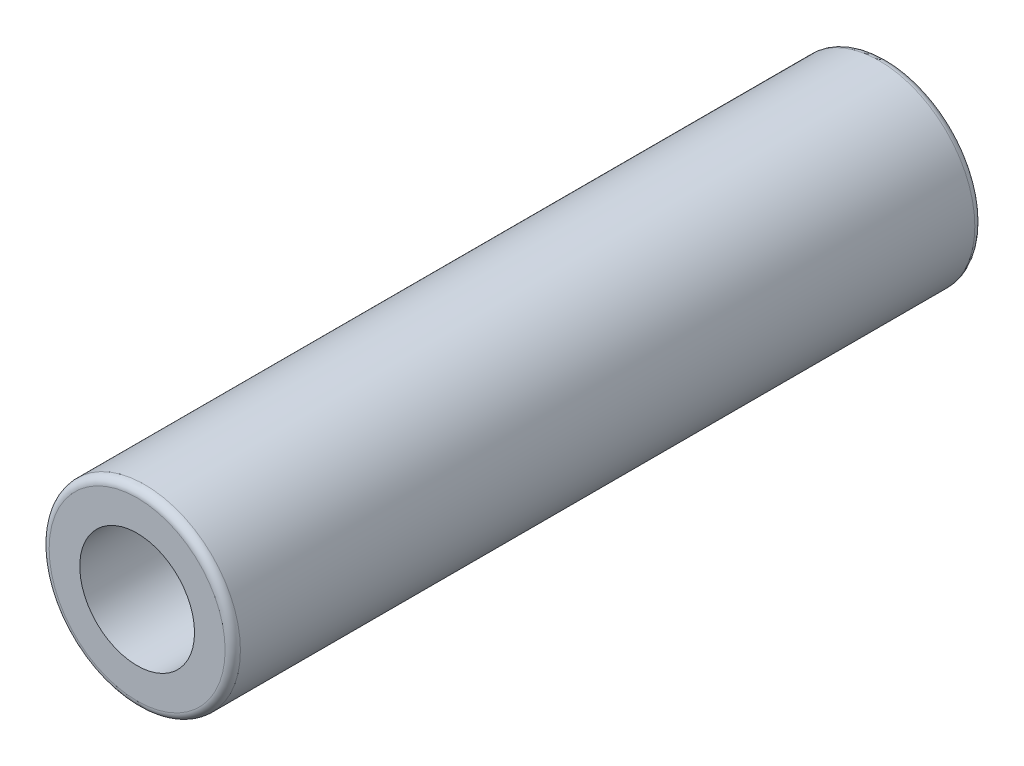
from build123d import *

# Parameters (mm, degrees)
SKETCH1_R           = 6.25
SKETCH1_R_2         = 3.75
EXTRUDE_THIN2_DEPTH = 24.5
FILLET4_R           = 0.5


with BuildPart() as part:
    # Sketch1 → Extrude-Thin2 (new body, symmetric)
    with BuildSketch(Plane.XY):
        Circle(SKETCH1_R)
        Circle(SKETCH1_R_2, mode=Mode.SUBTRACT)
    extrude(amount=EXTRUDE_THIN2_DEPTH, both=True)

    # Fillet4
    fillet4_edges = [part.edges().sort_by_distance(p)[0] for p in [
        (-6.25, 0, -24.5),
        (-6.25, 0, 24.5),
    ]]
    fillet(fillet4_edges, radius=FILLET4_R)


solid = part.part
